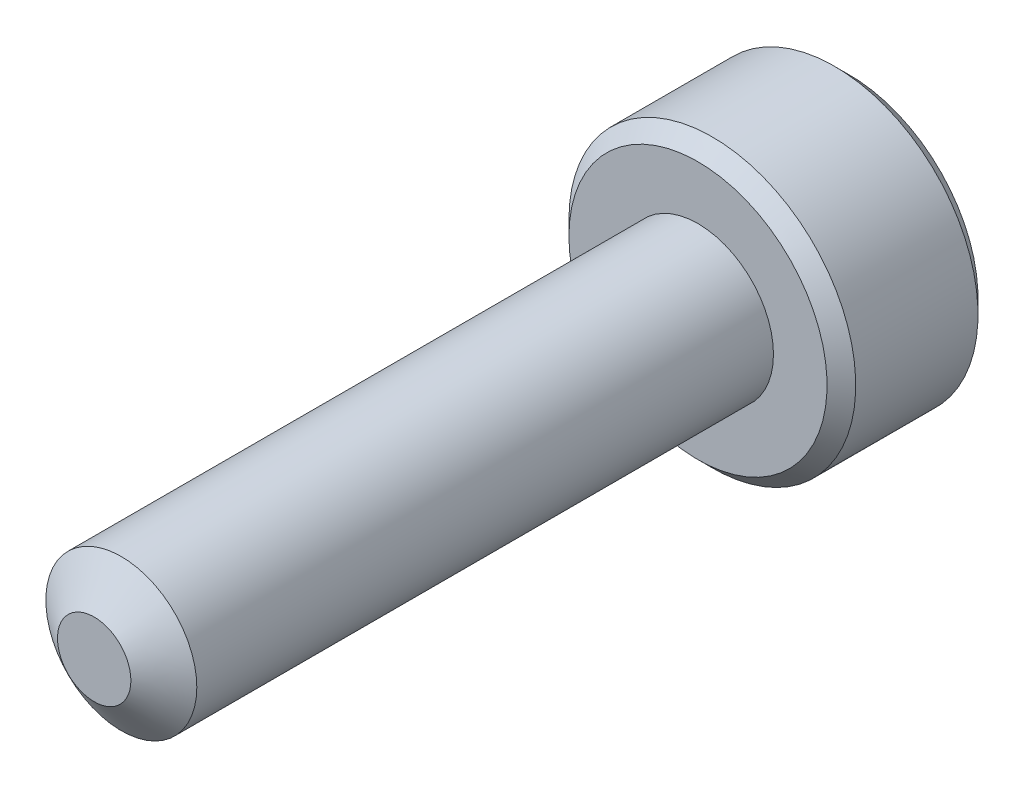
from build123d import *

# Parameters (mm, degrees)
SKETCH1_R          = 1
EXTRUDE1_DEPTH     = 8
SKETCH6_R          = 1.9
EXTRUDE2_DEPTH     = 2
CUT_EXTRUDE1_DEPTH = 1.125
CHAMFER1_SIZE      = 0.19


with BuildPart() as part:
    # Sketch1 → Extrude1 (new body)
    with BuildSketch(Plane.XY):
        Circle(SKETCH1_R)
    extrude(amount=-EXTRUDE1_DEPTH)

    # Sketch4 → Cut-Revolve1 (revolve, cut)
    with BuildSketch(Plane(origin=(0, 0, 0), x_dir=(0, 0, -1), z_dir=(1, 0, 0))):
        Polygon((0.35977197, 1), (0, 0.486192379), (0, 1), align=None)
    revolve(axis=Axis((0, 0, 0), (0, 0, -1)), mode=Mode.SUBTRACT)

    # Sketch6 → Extrude2 (add)
    with BuildSketch(Plane(origin=(0, 0, -8), x_dir=(-1, 0, 0), z_dir=(0, 0, -1))):
        Circle(SKETCH6_R)
    extrude(amount=EXTRUDE2_DEPTH)

    # Sketch7 → Cut-Extrude1 (cut)
    with BuildSketch(Plane(origin=(0, 0, -10), x_dir=(-1, 0, 0), z_dir=(0, 0, -1))):
        Polygon((0, 0.866025404), (-0.75, 0.433012702), (-0.75, -0.433012702), (0, -0.866025404), (0.75, -0.433012702), (0.75, 0.433012702), align=None)
    extrude(amount=-CUT_EXTRUDE1_DEPTH, mode=Mode.SUBTRACT)

    # Cut-Extrude2 cone 1 section (through the dimple's axis) → Cut-Extrude2 (revolve, cut)
    with BuildSketch(Plane(origin=(0, 0, -10), x_dir=(0, 1, 0), z_dir=(1, 0, 0))):
        Polygon((0, 0), (0.866025404, 0), (0, 0.866025404), align=None)
    revolve(axis=Axis((0, 0, -10), (0, 0, 1)), mode=Mode.SUBTRACT)

    # Chamfer1
    chamfer1_edges = [part.edges().sort_by_distance(p)[0] for p in [
        (1.9, 0, -10),
        (1.9, 0, -8),
    ]]
    chamfer(chamfer1_edges, length=CHAMFER1_SIZE)


solid = part.part
